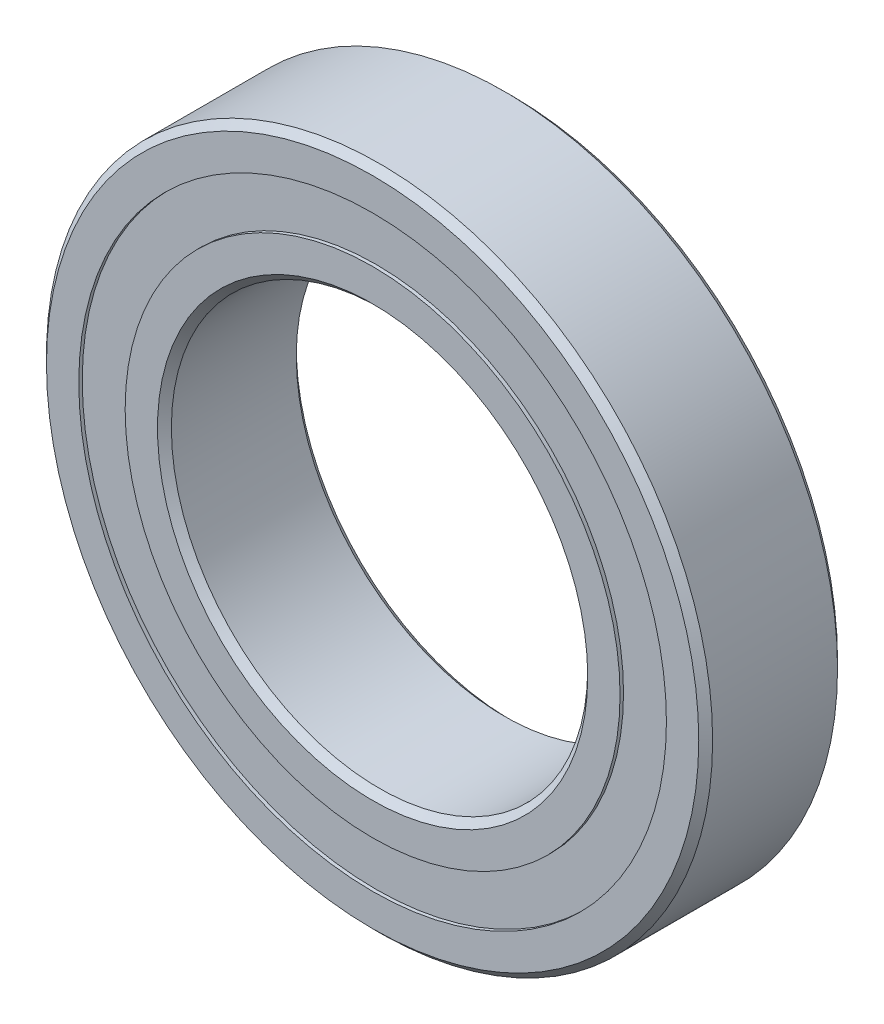
from build123d import *

# Parameters (mm, degrees)
CIRPATTERN1_COUNT = 12
SKETCH5_W         = 0.985011438
SKETCH5_H         = 1.67032967


with BuildPart() as part:
    # Sketch1 → Revolve1 (revolve)
    with BuildSketch(Plane(origin=(0, 0, 0), x_dir=(0, 0, -1), z_dir=(1, 0, 0))):
        with BuildLine():
            Line((2.25, 12), (-2.25, 12))
            Line((-2.25, 12), (-2.5, 11.75))
            Line((-2.5, 11.75), (-2.5, 10.585164835))
            Line((-2.5, 10.585164835), (-1.111111111, 10.585164835))
            ThreePointArc((-1.111111111, 10.585164835), (0, 11.139988562), (1.111111111, 10.585164835))
            Line((1.111111111, 10.585164835), (2.5, 10.585164835))
            Line((2.5, 10.585164835), (2.5, 11.75))
            Line((2.5, 11.75), (2.25, 12))
        make_face()
    revolve(axis=Axis((0, 0, 2.5), (0, 0, -1)))


with BuildPart() as body_2:
    # Sketch3 → Revolve3 (revolve)
    with BuildSketch(Plane(origin=(0, 0, 0), x_dir=(0, 0, -1), z_dir=(1, 0, 0))):
        with BuildLine():
            Line((-2.5, 8.914835165), (-1.111111111, 8.914835165))
            ThreePointArc((-1.111111111, 8.914835165), (0, 8.360011438), (1.111111111, 8.914835165))
            Line((1.111111111, 8.914835165), (2.5, 8.914835165))
            Line((2.5, 8.914835165), (2.5, 7.75))
            Line((2.5, 7.75), (2.25, 7.5))
            Line((2.25, 7.5), (-2.25, 7.5))
            Line((-2.25, 7.5), (-2.5, 7.75))
            Line((-2.5, 7.75), (-2.5, 8.914835165))
        make_face()
    revolve(axis=Axis((0, 0, 2.5), (0, 0, -1)))


with BuildPart() as body_3:
    # Sketch4 → Revolve4 (revolve)
    with BuildSketch(Plane(origin=(0, 0, 0), x_dir=(0, 0, -1), z_dir=(1, 0, 0))):
        with BuildLine():
            Line((-1.389988562, 9.75), (1.389988562, 9.75))
            ThreePointArc((1.389988562, 9.75), (0, 11.139988562), (-1.389988562, 9.75))
        make_face()
    revolve(axis=Axis((0, 9.75, 1.389988562), (0, 0, -1)))


with BuildPart() as cirpattern1_1:
    # CirPattern1: pattern copy
    add(body_3.part.rotate(Axis((0, 0, 0), (0, 0, 1)), 1 * 360 / CIRPATTERN1_COUNT))


with BuildPart() as cirpattern1_2:
    # CirPattern1: pattern copy
    add(body_3.part.rotate(Axis((0, 0, 0), (0, 0, 1)), 2 * 360 / CIRPATTERN1_COUNT))


with BuildPart() as cirpattern1_3:
    # CirPattern1: pattern copy
    add(body_3.part.rotate(Axis((0, 0, 0), (0, 0, 1)), 3 * 360 / CIRPATTERN1_COUNT))


with BuildPart() as cirpattern1_4:
    # CirPattern1: pattern copy
    add(body_3.part.rotate(Axis((0, 0, 0), (0, 0, 1)), 4 * 360 / CIRPATTERN1_COUNT))


with BuildPart() as cirpattern1_5:
    # CirPattern1: pattern copy
    add(body_3.part.rotate(Axis((0, 0, 0), (0, 0, 1)), 5 * 360 / CIRPATTERN1_COUNT))


with BuildPart() as cirpattern1_6:
    # CirPattern1: pattern copy
    add(body_3.part.rotate(Axis((0, 0, 0), (0, 0, 1)), 6 * 360 / CIRPATTERN1_COUNT))


with BuildPart() as cirpattern1_7:
    # CirPattern1: pattern copy
    add(body_3.part.rotate(Axis((0, 0, 0), (0, 0, 1)), 7 * 360 / CIRPATTERN1_COUNT))


with BuildPart() as cirpattern1_8:
    # CirPattern1: pattern copy
    add(body_3.part.rotate(Axis((0, 0, 0), (0, 0, 1)), 8 * 360 / CIRPATTERN1_COUNT))


with BuildPart() as cirpattern1_9:
    # CirPattern1: pattern copy
    add(body_3.part.rotate(Axis((0, 0, 0), (0, 0, 1)), 9 * 360 / CIRPATTERN1_COUNT))


with BuildPart() as cirpattern1_10:
    # CirPattern1: pattern copy
    add(body_3.part.rotate(Axis((0, 0, 0), (0, 0, 1)), 10 * 360 / CIRPATTERN1_COUNT))


with BuildPart() as cirpattern1_11:
    # CirPattern1: pattern copy
    add(body_3.part.rotate(Axis((0, 0, 0), (0, 0, 1)), 11 * 360 / CIRPATTERN1_COUNT))


with BuildPart() as body_15:
    # Sketch5 → Revolve5 (revolve)
    with BuildSketch(Plane(origin=(0, 0, 0), x_dir=(0, 0, -1), z_dir=(1, 0, 0))):
        with Locations((-1.882494281, 9.75)):
            Rectangle(SKETCH5_W, SKETCH5_H)
        with Locations((1.882494281, 9.75)):
            Rectangle(SKETCH5_W, SKETCH5_H)
    revolve(axis=Axis((0, 0, 2.5), (0, 0, -1)))


solid = Compound([part.part, body_2.part, body_3.part, cirpattern1_1.part, cirpattern1_2.part, cirpattern1_3.part, cirpattern1_4.part, cirpattern1_5.part, cirpattern1_6.part, cirpattern1_7.part, cirpattern1_8.part, cirpattern1_9.part, cirpattern1_10.part, cirpattern1_11.part, body_15.part])
